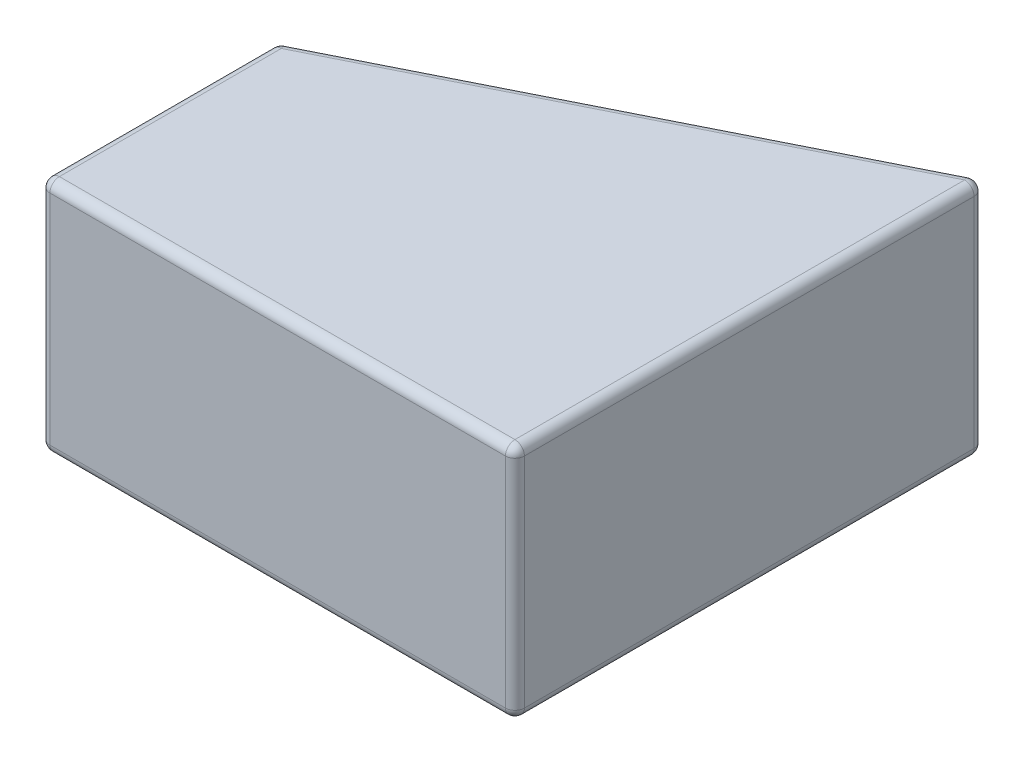
from build123d import *

# Parameters (mm, degrees)
SKETCH1_W           = 10
SKETCH1_H           = 5
BOSS_EXTRUDE1_DEPTH = 5
FILLET1_R           = 0.2


with BuildPart() as part:
    # Sketch1 → Boss-Extrude1 (new body)
    with BuildSketch(Plane(origin=(0, 0, 0), x_dir=(1, 0, 0), z_dir=(0, 1, 0))):
        Polygon((10, 10), (10, 5), (0, 5), align=None)
        with Locations((5, 2.5)):
            Rectangle(SKETCH1_W, SKETCH1_H)
    extrude(amount=BOSS_EXTRUDE1_DEPTH)

    # Fillet1
    fillet1_edges = [part.edges().sort_by_distance(p)[0] for p in [
        (5, 5, -7.5),
        (0, 5, -2.5),
        (5, 5, 0),
        (10, 5, -5),
        (5, 0, 0),
        (0, 0, -2.5),
        (5, 0, -7.5),
        (10, 0, -5),
        (10, 2.5, 0),
        (0, 2.5, 0),
        (0, 2.5, -5),
        (10, 2.5, -10),
    ]]
    fillet(fillet1_edges, radius=FILLET1_R)


solid = part.part
